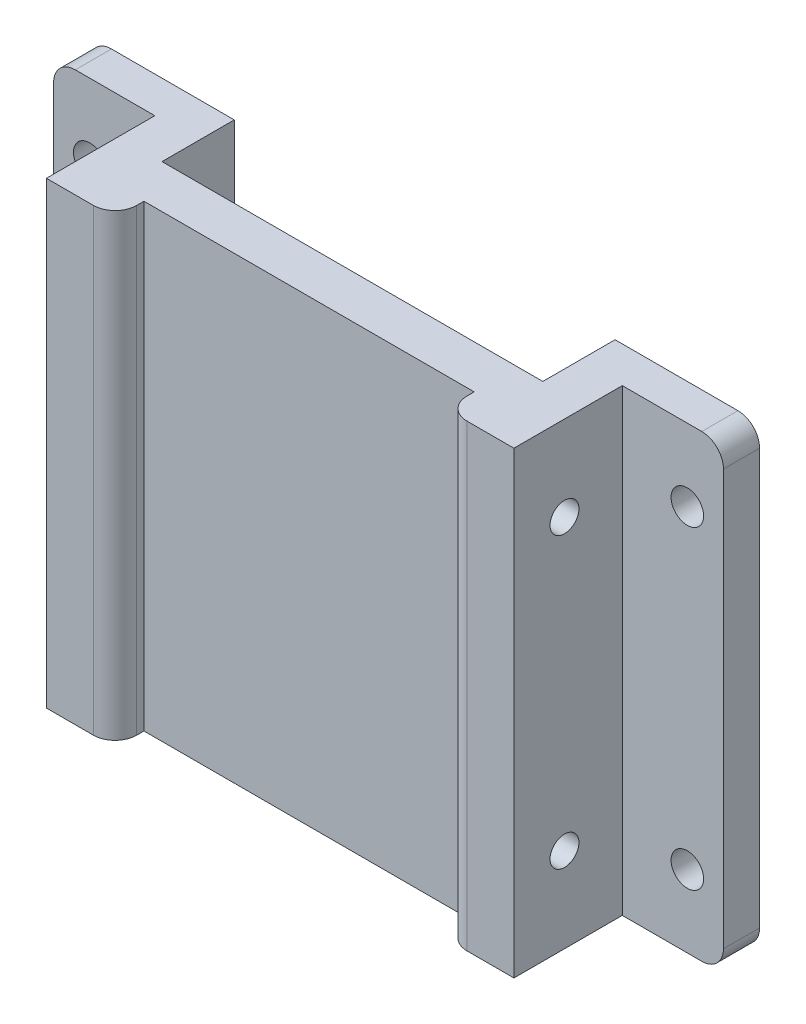
from build123d import *

# Parameters (mm, degrees)
SKETCH1_W             = 20
SKETCH1_H             = 63.5
BOSS_EXTRUDE1_DEPTH   = 5
BOSS_EXTRUDE1_2_DEPTH = 5
SKETCH2_W             = 6
SKETCH2_H             = 63.5
BOSS_EXTRUDE2_DEPTH   = 15
BOSS_EXTRUDE3_REACH   = 74.7
SKETCH3_W             = 6
SKETCH3_H             = 63.5
SKETCH4_W             = 4
SKETCH4_H             = 63.5
BOSS_EXTRUDE4_DEPTH   = 3.5
SKETCH6_R             = 2.25
CUT_EXTRUDE2_DEPTH    = 6
FILLET1_R             = 3
SKETCH7_R             = 2
CUT_EXTRUDE6_DEPTH    = 15


with BuildPart() as part:
    # Sketch1 → Boss-Extrude1 (new body)
    with BuildSketch(Plane.XY):
        with Locations((-36.35, 0)):
            Rectangle(SKETCH1_W, SKETCH1_H)
    extrude(amount=BOSS_EXTRUDE1_DEPTH)



with BuildPart() as body_2:
    # Sketch1 → Boss-Extrude1 2 (new body)
    with BuildSketch(Plane.XY):
        with Locations((36.35, 0)):
            Rectangle(SKETCH1_W, SKETCH1_H)
    extrude(amount=BOSS_EXTRUDE1_2_DEPTH)


with BuildPart() as part_1:
    add(part.part)

    add(body_2.part)  # Boss-Extrude2 merges body 2
    # Sketch2 → Boss-Extrude2 (add)
    with BuildSketch(Plane.XY.offset(5)):
        with Locations((-29.35, 0)):
            Rectangle(SKETCH2_W, SKETCH2_H)
        with Locations((29.35, 0)):
            Rectangle(SKETCH2_W, SKETCH2_H)
    extrude(amount=BOSS_EXTRUDE2_DEPTH)

    # Sketch3 → Boss-Extrude3 (add, up to next)
    with BuildSketch(Plane(origin=(-26.35, 0, 0), x_dir=(0, 0, -1), z_dir=(1, 0, 0)), mode=Mode.PRIVATE) as boss_extrude3_sk1:
        with Locations((-13, 0)):
            Rectangle(SKETCH3_W, SKETCH3_H)
    boss_extrude3_tool1 = extrude(boss_extrude3_sk1.sketch, amount=BOSS_EXTRUDE3_REACH, mode=Mode.PRIVATE) - part_1.part
    add(boss_extrude3_tool1.solids().sort_by_distance((-26.35, 0, 13))[0])

    # Sketch4 → Boss-Extrude4 (add)
    with BuildSketch(Plane(origin=(-26.35, 0, 0), x_dir=(0, 0, -1), z_dir=(1, 0, 0))):
        with Locations((-18, 0)):
            Rectangle(SKETCH4_W, SKETCH4_H)
    boss_extrude4 = extrude(amount=BOSS_EXTRUDE4_DEPTH)

    # Mirror1: Boss-Extrude4 across plane
    add(boss_extrude4.mirror(Plane(origin=(0, 0, 0), x_dir=(0, 0, 1), z_dir=(1, 0, 0))))

    # Sketch6 → Cut-Extrude2 (cut, through all)
    with BuildSketch(Plane.XY.offset(5)):
        with Locations((-41.35, 21.75)):
            Circle(SKETCH6_R)
        with Locations((-41.35, -21.75)):
            Circle(SKETCH6_R)
        with Locations((41.35, -21.75)):
            Circle(SKETCH6_R)
        with Locations((41.35, 21.75)):
            Circle(SKETCH6_R)
    extrude(amount=-CUT_EXTRUDE2_DEPTH, mode=Mode.SUBTRACT)

    # Fillet1
    fillet1_edges = [part_1.edges().sort_by_distance(p)[0] for p in [
        (46.35, 31.75, 2.5),
        (46.35, -31.75, 2.5),
        (-22.85, 0, 20),
        (22.85, 0, 20),
        (-46.35, 31.75, 2.5),
        (-46.35, -31.75, 2.5),
    ]]
    fillet(fillet1_edges, radius=FILLET1_R)

    # Sketch7 → Cut-Extrude6 (cut)
    with BuildSketch(Plane.ZY.offset(32.35)):
        with Locations((13, 20)):
            Circle(SKETCH7_R)
        with Locations((13, -20)):
            Circle(SKETCH7_R)
    cut_extrude6 = extrude(amount=-CUT_EXTRUDE6_DEPTH, mode=Mode.SUBTRACT)

    # Mirror2: Cut-Extrude6 across plane
    add(cut_extrude6.mirror(Plane(origin=(0, 0, 0), x_dir=(0, 0, 1), z_dir=(1, 0, 0))), mode=Mode.SUBTRACT)


solid = part_1.part
